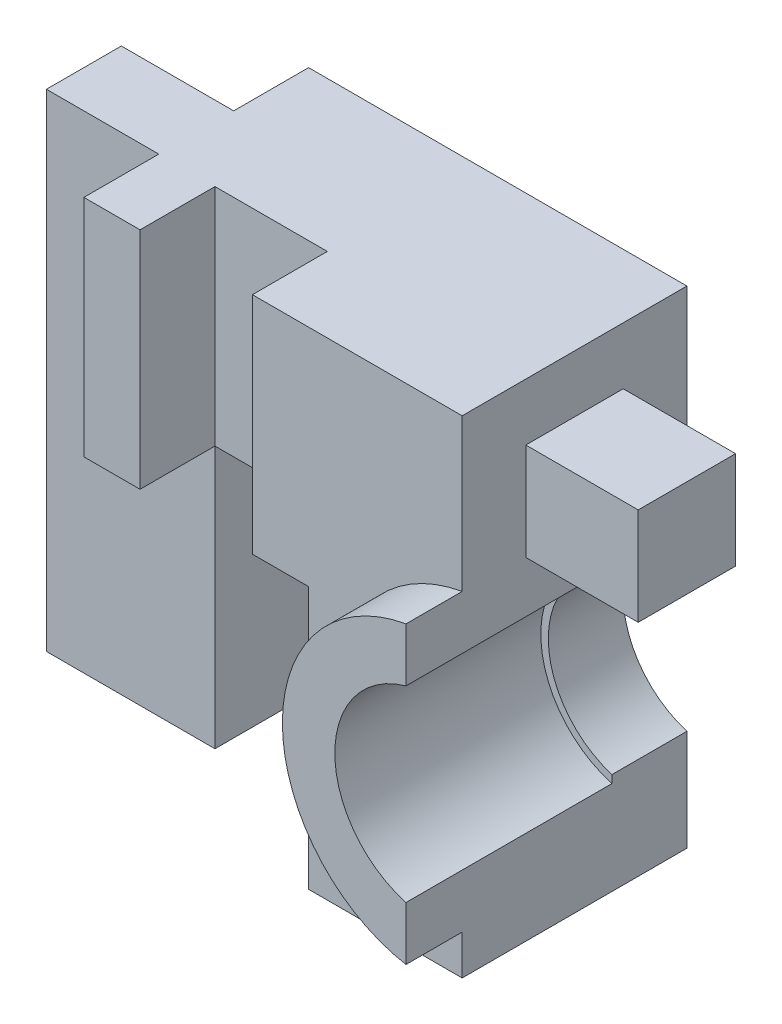
from build123d import *

# Parameters (mm, degrees)
SKETCH1_R            = 1
BOSS_EXTRUDE1_DEPTH  = 6
SKETCH2_R            = 2.6
CUT_EXTRUDE1_DEPTH   = 6
SKETCH3_W            = 7.6
SKETCH3_H            = 13
BOSS_EXTRUDE2_DEPTH  = 6
BOSS_EXTRUDE5_START  = -5
SKETCH6_W            = 3
SKETCH6_H            = 2
BOSS_EXTRUDE5_DEPTH  = 13
SKETCH10_R           = 4
SKETCH10_R_2         = 2.6
BOSS_EXTRUDE6_DEPTH  = 1.5
SKETCH12_R           = 2.6
SKETCH12_R_2         = 2.4
BOSS_EXTRUDE7_DEPTH  = 2
CUT_EXTRUDE2_DEPTH   = 7
SKETCH14_W           = 3
SKETCH14_H           = 2
CUT_EXTRUDE3_DEPTH   = 7
SKETCH15_W           = 0.2
SKETCH15_H           = 13
CUT_EXTRUDE4_DEPTH   = 9.5
SKETCH16_W           = 3
SKETCH16_H           = 3
CUT_EXTRUDE5_DEPTH   = 3
BOSS_EXTRUDE8_START  = 0.2
SKETCH16_3_W         = 2.6
SKETCH16_3_H         = 2.6
BOSS_EXTRUDE8_DEPTH  = 3
BOSS_EXTRUDE9_START  = -24.2
SKETCH16_4_W         = 2.6
SKETCH16_4_H         = 2.6
BOSS_EXTRUDE9_DEPTH  = 3
SKETCH17_W           = 29.7
SKETCH17_H           = 13
CUT_EXTRUDE6_DEPTH   = 10
SKETCH18_W           = 2.6
SKETCH18_H           = 2.6
BOSS_EXTRUDE10_DEPTH = 3


with BuildPart() as part:
    # Sketch1 → Boss-Extrude1 (new body)
    with BuildSketch(Plane.XY):
        with BuildLine():
            ThreePointArc((3.75, -5), (4.47902769, -4.358991965), (5.1, -3.61282438))
            Line((5.1, -3.61282438), (5.1, 3.61282438))
            ThreePointArc((5.1, 3.61282438), (0, 6.25), (-5.1, 3.61282438))
            Line((-5.1, 3.61282438), (-5.1, -3.61282438))
            ThreePointArc((-5.1, -3.61282438), (-4.47902769, -4.358991965), (-3.75, -5))
            Line((-3.75, -5), (-14.7, -5))
            Line((-14.7, -5), (-14.7, 8))
            Line((-14.7, 8), (14.7, 8))
            Line((14.7, 8), (14.7, -5))
            Line((14.7, -5), (3.75, -5))
        make_face()
        with Locations((11.5, 0)):
            Circle(SKETCH1_R, mode=Mode.SUBTRACT)
        with Locations((-11.5, 0)):
            Circle(SKETCH1_R, mode=Mode.SUBTRACT)
    extrude(amount=BOSS_EXTRUDE1_DEPTH)

    # Sketch2 → Cut-Extrude1 (cut)
    with BuildSketch(Plane.XY):
        with Locations((-11.5, 0)):
            Circle(SKETCH2_R)
        with Locations((11.5, 0)):
            Circle(SKETCH2_R)
    extrude(amount=CUT_EXTRUDE1_DEPTH, mode=Mode.SUBTRACT)

    # Sketch3 → Boss-Extrude2 (add)
    with BuildSketch(Plane.XY):
        with Locations((-18.5, 1.5)):
            Rectangle(SKETCH3_W, SKETCH3_H)
    extrude(amount=BOSS_EXTRUDE2_DEPTH)

    # Sketch6 → Boss-Extrude5 (add)
    with BuildSketch(Plane(origin=(0, 0, 0), x_dir=(1, 0, 0), z_dir=(0, 1, 0)).offset(BOSS_EXTRUDE5_START)):
        with Locations((-23.8, -3)):
            Rectangle(SKETCH6_W, SKETCH6_H)
        with Locations((16.2, -3)):
            Rectangle(SKETCH6_W, SKETCH6_H)
    extrude(amount=BOSS_EXTRUDE5_DEPTH)

    # Sketch10 → Boss-Extrude6 (add)
    with BuildSketch(Plane.XY.offset(6)):
        with Locations((-11.5, 0)):
            Circle(SKETCH10_R)
        with Locations((-11.5, 0)):
            Circle(SKETCH10_R_2, mode=Mode.SUBTRACT)
        with BuildLine():
            Line((14.7, 2.4), (14.7, -2.4))
            ThreePointArc((14.7, -2.4), (7.5, 0), (14.7, 2.4))
        make_face()
        with Locations((11.5, 0)):
            Circle(SKETCH10_R_2, mode=Mode.SUBTRACT)
    extrude(amount=BOSS_EXTRUDE6_DEPTH)

    # Sketch12 → Boss-Extrude7 (add)
    with BuildSketch(Plane(origin=(0, 0, 0), x_dir=(-1, 0, 0), z_dir=(0, 0, -1))):
        with Locations((11.5, 0)):
            Circle(SKETCH12_R)
        with Locations((11.5, 0)):
            Circle(SKETCH12_R_2, mode=Mode.SUBTRACT)
        with Locations((-11.5, 0)):
            Circle(SKETCH12_R)
        with Locations((-11.5, 0)):
            Circle(SKETCH12_R_2, mode=Mode.SUBTRACT)
    extrude(amount=-BOSS_EXTRUDE7_DEPTH)

    # Sketch13 → Cut-Extrude2 (cut)
    with BuildSketch(Plane.XZ.offset(5)):
        Polygon((-22.3, 6), (-16.3, 6), (-16.3, 4), (-17.8, 4), (-17.8, 0), (-20.8, 0), (-20.8, 4), (-22.3, 4), align=None)
    extrude(amount=-CUT_EXTRUDE2_DEPTH, mode=Mode.SUBTRACT)

    # Sketch14 → Cut-Extrude3 (cut)
    with BuildSketch(Plane.XZ.offset(-2)):
        with Locations((-19.3, 5)):
            Rectangle(SKETCH14_W, SKETCH14_H)
    extrude(amount=-CUT_EXTRUDE3_DEPTH, mode=Mode.SUBTRACT)

    # Sketch15 → Cut-Extrude4 (cut, symmetric)
    with BuildSketch(Plane.XY):
        with Locations((-12.1, 1.5)):
            Rectangle(SKETCH15_W, SKETCH15_H)
        with Locations((12.1, 1.5)):
            Rectangle(SKETCH15_W, SKETCH15_H)
    extrude(amount=CUT_EXTRUDE4_DEPTH, both=True, mode=Mode.SUBTRACT)

    # Sketch16 → Cut-Extrude5 (cut)
    with BuildSketch(Plane.ZY.offset(12)):
        with Locations((3, 5.173669459)):
            Rectangle(SKETCH16_W, SKETCH16_H)
    cut_extrude5 = extrude(amount=-CUT_EXTRUDE5_DEPTH, mode=Mode.SUBTRACT)

    # Mirror1: Cut-Extrude5 across plane
    add(cut_extrude5.mirror(Plane(origin=(0, 0, 0), x_dir=(0, 0, 1), z_dir=(1, 0, 0))), mode=Mode.SUBTRACT)

    # Sketch16_3 → Boss-Extrude8 (add)
    with BuildSketch(Plane.ZY.offset(12).offset(BOSS_EXTRUDE8_START)):
        with Locations((3, 5.173669459)):
            Rectangle(SKETCH16_3_W, SKETCH16_3_H)
    extrude(amount=-BOSS_EXTRUDE8_DEPTH)

    # Sketch16_4 → Boss-Extrude9 (add)
    with BuildSketch(Plane.ZY.offset(12).offset(BOSS_EXTRUDE9_START)):
        with Locations((3, 5.173669459)):
            Rectangle(SKETCH16_4_W, SKETCH16_4_H)
    extrude(amount=BOSS_EXTRUDE9_DEPTH)

    # Sketch17 → Cut-Extrude6 (cut)
    with BuildSketch(Plane.XY):
        with Locations((2.85, 1.5)):
            Rectangle(SKETCH17_W, SKETCH17_H)
    extrude(amount=CUT_EXTRUDE6_DEPTH, mode=Mode.SUBTRACT)

    # Sketch18 → Boss-Extrude10 (add)
    with BuildSketch(Plane(origin=(-12.2, 0, 0), x_dir=(0, 0, -1), z_dir=(1, 0, 0))):
        with Locations((-3, 5.173669459)):
            Rectangle(SKETCH18_W, SKETCH18_H)
    extrude(amount=BOSS_EXTRUDE10_DEPTH)


solid = part.part
